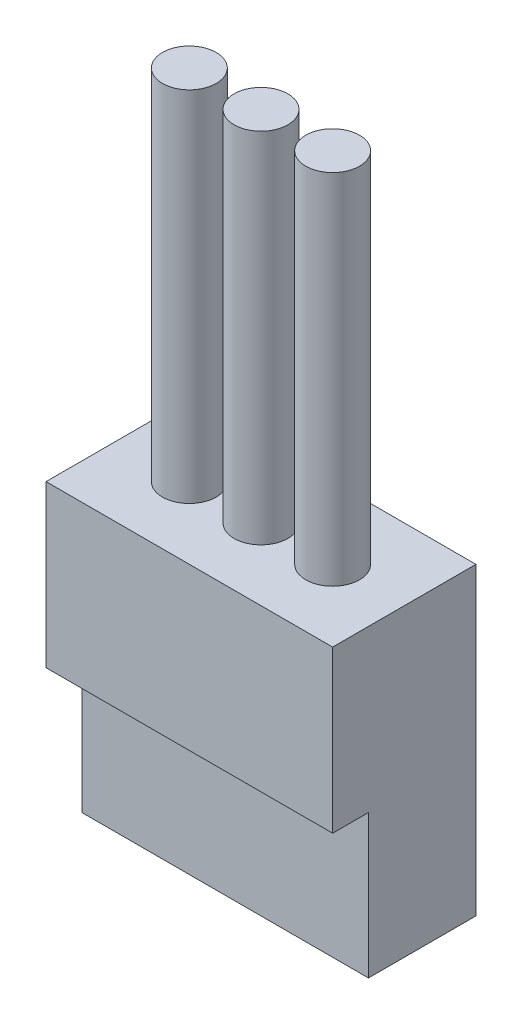
from build123d import *

# Parameters (mm, degrees)
ESQUISSE1_W      = 8
ESQUISSE1_H      = 3
EXTRUSION1_DEPTH = 4
ESQUISSE2_W      = 8
ESQUISSE2_H      = 4
EXTRUSION2_DEPTH = 4.5
ESQUISSE3_R      = 0.75
EXTRUSION3_DEPTH = 10


with BuildPart() as part:
    # Esquisse1 → Extrusion1 (new body)
    with BuildSketch(Plane(origin=(0, 0, 0), x_dir=(1, 0, 0), z_dir=(0, 1, 0))):
        with Locations((4, -1.5)):
            Rectangle(ESQUISSE1_W, ESQUISSE1_H)
    extrude(amount=EXTRUSION1_DEPTH)

    # Esquisse2 → Extrusion2 (add)
    with BuildSketch(Plane(origin=(0, 4, 0), x_dir=(1, 0, 0), z_dir=(0, 1, 0))):
        with Locations((4, -2)):
            Rectangle(ESQUISSE2_W, ESQUISSE2_H)
    extrude(amount=EXTRUSION2_DEPTH)

    # Esquisse3 → Extrusion3 (add)
    with BuildSketch(Plane(origin=(0, 8.5, 0), x_dir=(1, 0, 0), z_dir=(0, 1, 0))):
        with Locations((4, -2)):
            Circle(ESQUISSE3_R)
        with Locations((2, -2)):
            Circle(ESQUISSE3_R)
        with Locations((6, -2)):
            Circle(ESQUISSE3_R)
    extrude(amount=EXTRUSION3_DEPTH)


solid = part.part
